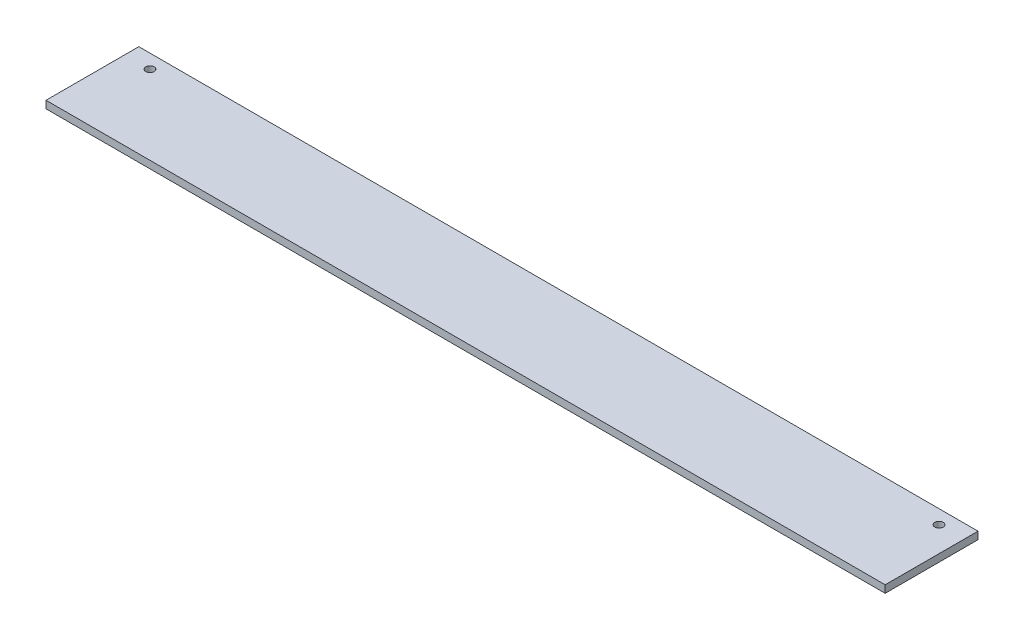
from build123d import *

# Parameters (mm, degrees)
SKETCH_1_W          = 50
SKETCH_1_H          = 4
EXTRUDE_1_DEPTH     = 452
SKETCH_2_R          = 2.25
CUT_EXTRUDE_1_DEPTH = 5


with BuildPart() as part:
    # Эскиз1 → Бобышка-Вытянуть1 (new body)
    with BuildSketch(Plane(origin=(0, 0, 0), x_dir=(0, 0, -1), z_dir=(1, 0, 0))):
        Rectangle(SKETCH_1_W, SKETCH_1_H)
    extrude(amount=EXTRUDE_1_DEPTH)

    # Эскиз2 → Вырез-Вытянуть1 (cut, through all)
    with BuildSketch(Plane(origin=(0, 2, 0), x_dir=(1, 0, 0), z_dir=(0, 1, 0))):
        with Locations((13.5, 17.5)):
            Circle(SKETCH_2_R)
        with Locations((438.5, 17.5)):
            Circle(SKETCH_2_R)
    extrude(amount=-CUT_EXTRUDE_1_DEPTH, mode=Mode.SUBTRACT)


solid = part.part
